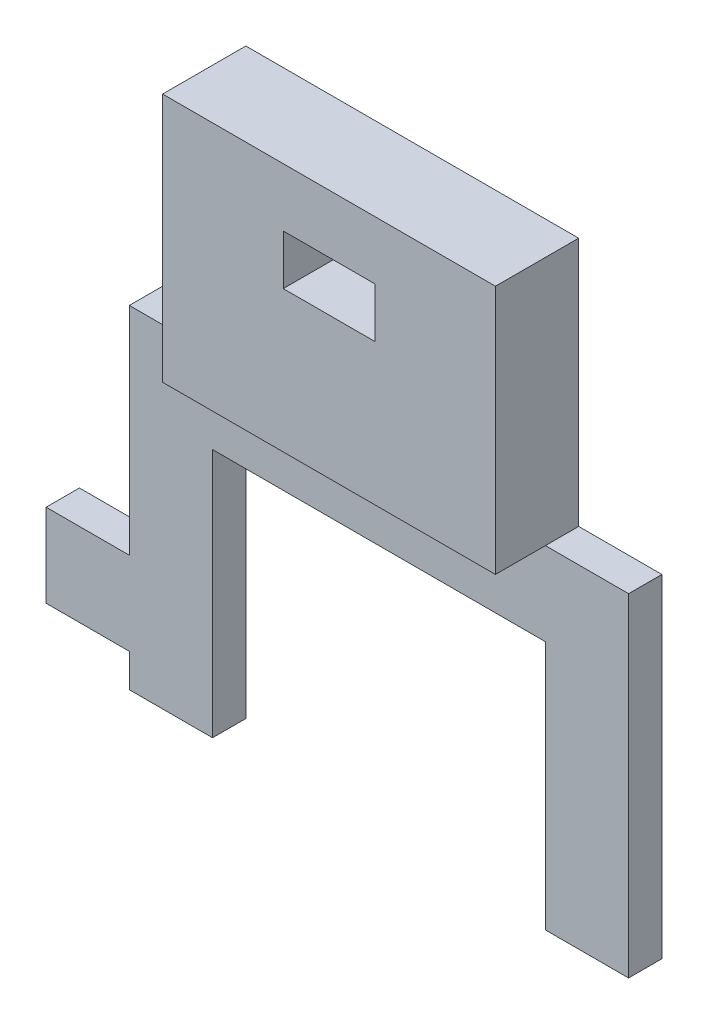
from build123d import *

# Parameters (mm, degrees)
P_IDAT_VYSUNUT_M1_DEPTH  = 2
SKICA2_W                 = 20
SKICA2_H                 = 2
P_IDAT_VYSUNUT_M2_DEPTH  = 15
SKICA3_W                 = 5.5
SKICA3_H                 = 3
ODEBRAT_VYSUNUT_M1_DEPTH = 15
SKICA5_W                 = 20
SKICA5_H                 = 15
SKICA5_W_2               = 5.5
SKICA5_H_2               = 3
P_IDAT_VYSUNUT_M3_DEPTH  = 3


with BuildPart() as part:
    # Skica1 → Přidat vysunutím1 (new body)
    with BuildSketch(Plane.XY):
        Polygon((0, 0), (5, 0), (5, -2), (10, -2), (10, 4.082474227), (10, 13), (30, 13), (30, -2), (35, -2), (35, 18), (5, 18), (5, 5), (0, 5), align=None)
    extrude(amount=P_IDAT_VYSUNUT_M1_DEPTH)

    # Skica2 → Přidat vysunutím2 (add)
    with BuildSketch(Plane(origin=(0, 18, 0), x_dir=(1, 0, 0), z_dir=(0, 1, 0))):
        with Locations((20, -1)):
            Rectangle(SKICA2_W, SKICA2_H)
    extrude(amount=P_IDAT_VYSUNUT_M2_DEPTH)

    # Skica3 → Odebrat vysunutím1 (cut)
    with BuildSketch(Plane.XY.offset(2)):
        with Locations((20, 28)):
            Rectangle(SKICA3_W, SKICA3_H)
    extrude(amount=-ODEBRAT_VYSUNUT_M1_DEPTH, mode=Mode.SUBTRACT)

    # Skica5 → Přidat vysunutím3 (add)
    with BuildSketch(Plane.XY.offset(2)):
        with Locations((20, 25.5)):
            Rectangle(SKICA5_W, SKICA5_H)
        with Locations((20, 28)):
            Rectangle(SKICA5_W_2, SKICA5_H_2, mode=Mode.SUBTRACT)
    extrude(amount=P_IDAT_VYSUNUT_M3_DEPTH)


solid = part.part
